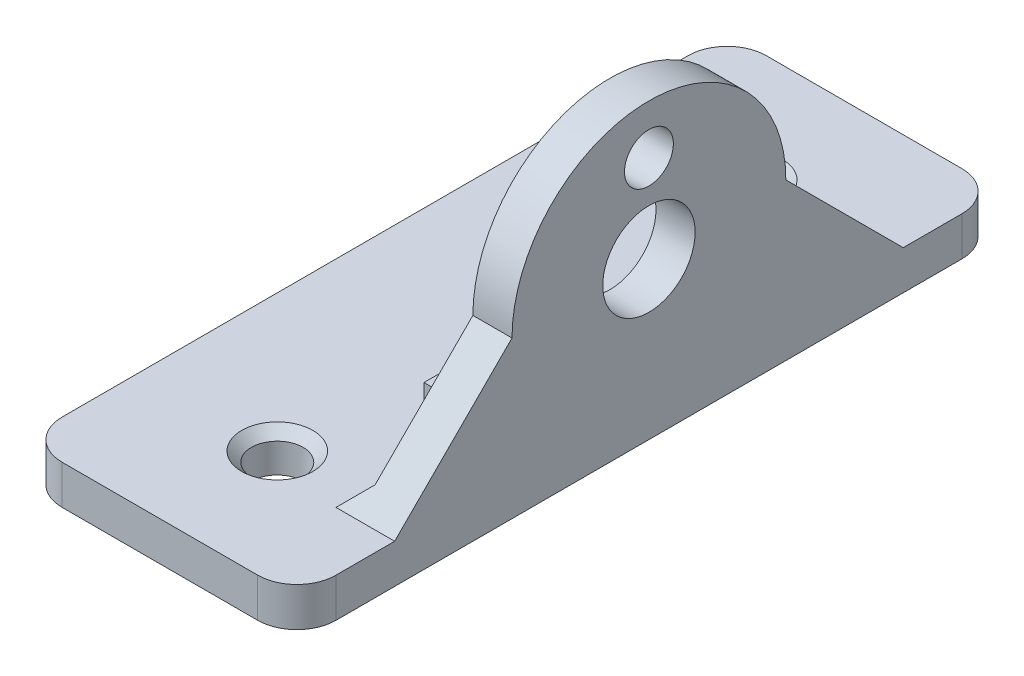
from build123d import *

# Parameters (mm, degrees)
SKETCH1_R           = 3.75
BOSS_EXTRUDE1_DEPTH = 3.175
SKETCH2_R           = 1.984375
CUT_EXTRUDE1_DEPTH  = 4.175
SKETCH3_W           = 57.15
SKETCH3_H           = 3.175
BOSS_EXTRUDE2_DEPTH = 19.05
SKETCH4_W           = 2.38125
SKETCH4_H           = 2.032
BOSS_EXTRUDE3_DEPTH = 4.7625
SKETCH5_R           = 2.0955
CUT_EXTRUDE2_DEPTH  = 4.175
CHAMFER1_SIZE       = 0.79375
CHAMFER3_SIZE       = 1.5875
FILLET1_R           = 3.175


with BuildPart() as part:
    # Sketch1 → Boss-Extrude1 (new body)
    with BuildSketch(Plane(origin=(0, 0, 0), x_dir=(0, 0, -1), z_dir=(1, 0, 0))):
        with BuildLine():
            Line((-28.575, 0), (28.575, 0))
            Line((28.575, 0), (28.575, 3.175))
            Line((28.575, 3.175), (20.6375, 3.175))
            Line((20.6375, 3.175), (11.1125, 12.7))
            ThreePointArc((11.1125, 12.7), (0, 23.8125), (-11.1125, 12.7))
            Line((-11.1125, 12.7), (-20.6375, 3.175))
            Line((-20.6375, 3.175), (-28.575, 3.175))
            Line((-28.575, 3.175), (-28.575, 0))
        make_face()
        with Locations((0, 12.7)):
            Circle(SKETCH1_R, mode=Mode.SUBTRACT)
    extrude(amount=-BOSS_EXTRUDE1_DEPTH)

    # Sketch2 → Cut-Extrude1 (cut, through all)
    with BuildSketch(Plane(origin=(0, 0, 0), x_dir=(0, 0, -1), z_dir=(1, 0, 0))):
        with Locations((0, 19.812)):
            Circle(SKETCH2_R)
    extrude(amount=-CUT_EXTRUDE1_DEPTH, mode=Mode.SUBTRACT)

    # Sketch3 → Boss-Extrude2 (add)
    with BuildSketch(Plane.ZY.offset(3.175)):
        with Locations((0, 1.5875)):
            Rectangle(SKETCH3_W, SKETCH3_H)
    extrude(amount=BOSS_EXTRUDE2_DEPTH)

    # Sketch4 → Boss-Extrude3 (add)
    with BuildSketch(Plane.ZY.offset(3.175)):
        with Locations((9.128125, 4.191)):
            Rectangle(SKETCH4_W, SKETCH4_H)
    extrude(amount=BOSS_EXTRUDE3_DEPTH)

    # Sketch5 → Cut-Extrude2 (cut, through all)
    with BuildSketch(Plane(origin=(0, 3.175, 0), x_dir=(1, 0, 0), z_dir=(0, 1, 0))):
        with Locations((-11.1125, -19.05)):
            Circle(SKETCH5_R)
        with Locations((-11.1125, 19.05)):
            Circle(SKETCH5_R)
    extrude(amount=-CUT_EXTRUDE2_DEPTH, mode=Mode.SUBTRACT)

    # Chamfer1
    chamfer1_edges = [part.edges().sort_by_distance(p)[0] for p in [
        (-13.208, 3.175, 19.05),
        (-13.208, 3.175, -19.05),
    ]]
    chamfer(chamfer1_edges, length=CHAMFER1_SIZE)

    # Chamfer3
    chamfer3_edges = [part.edges().sort_by_distance(p)[0] for p in [
        (-3.175, 3.175, 15.478125),
        (-3.175, 3.175, -6.35),
    ]]
    chamfer(chamfer3_edges, length=CHAMFER3_SIZE)

    # Fillet1
    fillet1_edges = [part.edges().sort_by_distance(p)[0] for p in [
        (0, 1.5875, -28.575),
        (0, 1.5875, 28.575),
        (-22.225, 1.5875, -28.575),
        (-22.225, 1.5875, 28.575),
    ]]
    fillet(fillet1_edges, radius=FILLET1_R)


solid = part.part
